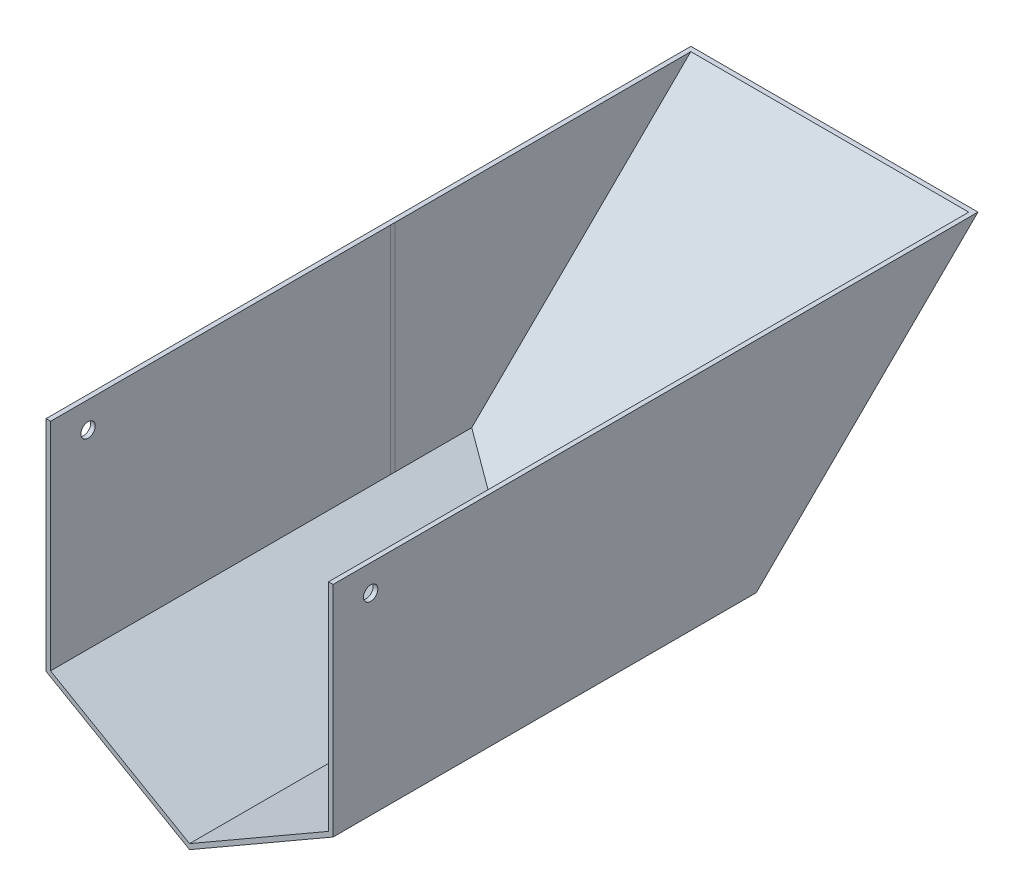
from build123d import *

# Parameters (mm, degrees)
BOSS_EXTRUDE2_DEPTH             = 76.2
BOSS_EXTRUDE3_DEPTH             = 118.4125
SKETCH5_W                       = 96.825174549
SKETCH5_H                       = 1.5875
CUT_EXTRUDE2_DEPTH              = 76.2
BOSS_EXTRUDE5_REACH             = 52
BOSS_EXTRUDE5_DIRECTION_2_REACH = 52
BOSS_EXTRUDE6_REACH             = 122.202
BOSS_EXTRUDE7_DEPTH             = 1.5875
BOSS_EXTRUDE8_DEPTH             = 1.5875
SKETCH15_W                      = 143.32634152
SKETCH15_H                      = 53.255725939
CUT_EXTRUDE3_DEPTH              = 264.5875
CUT_EXTRUDE4_DEPTH              = 264.5875
SKETCH18_R                      = 2.5
CUT_EXTRUDE5_DEPTH              = 264.5875


with BuildPart() as part:
    # Sketch1 → Boss-Extrude2 (new body)
    with BuildSketch(Plane(origin=(0, 0, 0), x_dir=(1, 0, 0), z_dir=(0, 1, 0))):
        Polygon((1.5875, -1.5875), (98.4125, -1.5875), (98.4125, -118.4125), (98.4125, -120), (100, -120), (100, 0), (0, 0), (0, -120), (1.5875, -120), (1.5875, -118.4125), align=None)
    extrude(amount=BOSS_EXTRUDE2_DEPTH)

    # Sketch2 → Boss-Extrude3 (add)
    with BuildSketch(Plane.XY.offset(120)):
        Polygon((0, 0), (1.5875, 0.917396042), (50, -26.981614962), (98.4125, 0.917396042), (100, 0), (50, -28.813850766), align=None)
    extrude(amount=-BOSS_EXTRUDE3_DEPTH)

    # Sketch5 → Cut-Extrude2 (cut)
    with BuildSketch(Plane(origin=(0, 76.2, 0), x_dir=(1, 0, 0), z_dir=(0, 1, 0))):
        with Locations((49.999912726, -0.79375)):
            Rectangle(SKETCH5_W, SKETCH5_H)
    extrude(amount=-CUT_EXTRUDE2_DEPTH, mode=Mode.SUBTRACT)

    # Boss-Extrude5: up to this face of the body (flat: up to its plane)
    boss_extrude5_end = Plane(part.part.faces().sort_by_distance((0, 38.1, 60))[0])
    # Sketch11 → Boss-Extrude5 (add, up to the picked face)
    with BuildSketch(Plane.ZY.offset(-50), mode=Mode.PRIVATE) as boss_extrude5_sk1:
        Polygon((1.5875, -26.981614962), (1.5875, -28.813850766), (-27.384499219, 0), (-25.76142568, 0), align=None)
    boss_extrude5_tool1 = split(extrude(boss_extrude5_sk1.sketch, amount=BOSS_EXTRUDE5_REACH, mode=Mode.PRIVATE), bisect_by=boss_extrude5_end, keep=Keep.BOTH, mode=Mode.PRIVATE)
    add(boss_extrude5_tool1.solids().sort_by_distance((50, -14.256717, -12.190864))[0])
    # Sketch11 → Boss-Extrude5 (add, up to the picked face)
    with BuildSketch(Plane.ZY.offset(-50), mode=Mode.PRIVATE) as boss_extrude5_sk2:
        Polygon((-27.384499219, 0), (-25.76142568, 0), (-117.814066128, 90.816324189), (-118.614630338, 90.004861602), align=None)
    boss_extrude5_tool2 = split(extrude(boss_extrude5_sk2.sketch, amount=BOSS_EXTRUDE5_REACH, mode=Mode.PRIVATE), bisect_by=boss_extrude5_end, keep=Keep.BOTH, mode=Mode.PRIVATE)
    add(boss_extrude5_tool2.solids().sort_by_distance((50, 45.2056, -72.392749))[0])

    # Boss-Extrude5 direction 2: up to this face of the body (flat: up to its plane)
    boss_extrude5_direction_2_end = Plane(part.part.faces().sort_by_distance((100, 38.1, 60))[0])
    # Sketch11 → Boss-Extrude5 direction 2 (add, up to the picked face)
    with BuildSketch(Plane.ZY.offset(-50), mode=Mode.PRIVATE) as boss_extrude5_direction_2_sk1:
        Polygon((1.5875, -26.981614962), (1.5875, -28.813850766), (-27.384499219, 0), (-25.76142568, 0), align=None)
    boss_extrude5_direction_2_tool1 = split(extrude(boss_extrude5_direction_2_sk1.sketch, amount=-BOSS_EXTRUDE5_DIRECTION_2_REACH, mode=Mode.PRIVATE), bisect_by=boss_extrude5_direction_2_end, keep=Keep.BOTH, mode=Mode.PRIVATE)
    add(boss_extrude5_direction_2_tool1.solids().sort_by_distance((50, -14.256717, -12.190864))[0])
    # Sketch11 → Boss-Extrude5 direction 2 (add, up to the picked face)
    with BuildSketch(Plane.ZY.offset(-50), mode=Mode.PRIVATE) as boss_extrude5_direction_2_sk2:
        Polygon((-27.384499219, 0), (-25.76142568, 0), (-117.814066128, 90.816324189), (-118.614630338, 90.004861602), align=None)
    boss_extrude5_direction_2_tool2 = split(extrude(boss_extrude5_direction_2_sk2.sketch, amount=-BOSS_EXTRUDE5_DIRECTION_2_REACH, mode=Mode.PRIVATE), bisect_by=boss_extrude5_direction_2_end, keep=Keep.BOTH, mode=Mode.PRIVATE)
    add(boss_extrude5_direction_2_tool2.solids().sort_by_distance((50, 45.2056, -72.392749))[0])

    # Boss-Extrude6: up to this face of the body (flat: up to its plane)
    boss_extrude6_end = Plane(part.part.faces().sort_by_distance((50, -14.406925383, -12.89849961))[0])
    # Sketch12 → Boss-Extrude6 (add, up to the picked face)
    with BuildSketch(Plane(origin=(0, 0, 1.5875), x_dir=(-1, 0, 0), z_dir=(0, 0, -1)), mode=Mode.PRIVATE) as boss_extrude6_sk1:
        Polygon((-50, -26.981614962), (-98.4125, 0.917396042), (-98.4125, 0), (-100, 0), (-53.179435853, -26.981614962), (-50, -28.813850766), (-46.820564147, -26.981614962), (0, 0), (0, 0.917396042), (-1.5875, 0.917396042), align=None)
    boss_extrude6_tool1 = split(extrude(boss_extrude6_sk1.sketch, amount=BOSS_EXTRUDE6_REACH, mode=Mode.PRIVATE), bisect_by=boss_extrude6_end, keep=Keep.BOTH, mode=Mode.PRIVATE)
    add(boss_extrude6_tool1.solids().sort_by_distance((25.272847, -13.93602, 1.5875))[0])

    # Sketch13 → Boss-Extrude7 (add)
    with BuildSketch(Plane.ZY):
        Polygon((0, 0.917396042), (0, 76.2), (-102.998764504, 76.2), (-26.691310574, 0.917396042), align=None)
    extrude(amount=-BOSS_EXTRUDE7_DEPTH)

    # Sketch14 → Boss-Extrude8 (add)
    with BuildSketch(Plane(origin=(100, 0, 0), x_dir=(0, 0, -1), z_dir=(1, 0, 0))):
        Polygon((0, 0), (25.76142568, 0), (102.998764504, 76.2), (0, 76.2), align=None)
    extrude(amount=-BOSS_EXTRUDE8_DEPTH)

    # Sketch15 → Cut-Extrude3 (cut)
    with BuildSketch(Plane.XY.offset(120)):
        with Locations((28.33682924, 102.82786297)):
            Rectangle(SKETCH15_W, SKETCH15_H)
    extrude(amount=-CUT_EXTRUDE3_DEPTH, mode=Mode.SUBTRACT)

    # Sketch16 → Cut-Extrude4 (cut)
    with BuildSketch(Plane.XY.offset(120)):
        Polygon((63.760723445, -52.692511686), (50, -28.813850766), (100, 0), (131.48806996, 0), (150.508378032, -66.092213095), align=None)
        Polygon((-24.631729482, 0), (0, 0), (50, -28.813850766), (-14.891819722, -42.472870615), align=None)
    extrude(amount=-CUT_EXTRUDE4_DEPTH, mode=Mode.SUBTRACT)

    # Sketch18 → Cut-Extrude5 (cut)
    with BuildSketch(Plane.ZY):
        with Locations((106.931013832, 67.039572628)):
            Circle(SKETCH18_R)
    extrude(amount=-CUT_EXTRUDE5_DEPTH, mode=Mode.SUBTRACT)


solid = part.part
